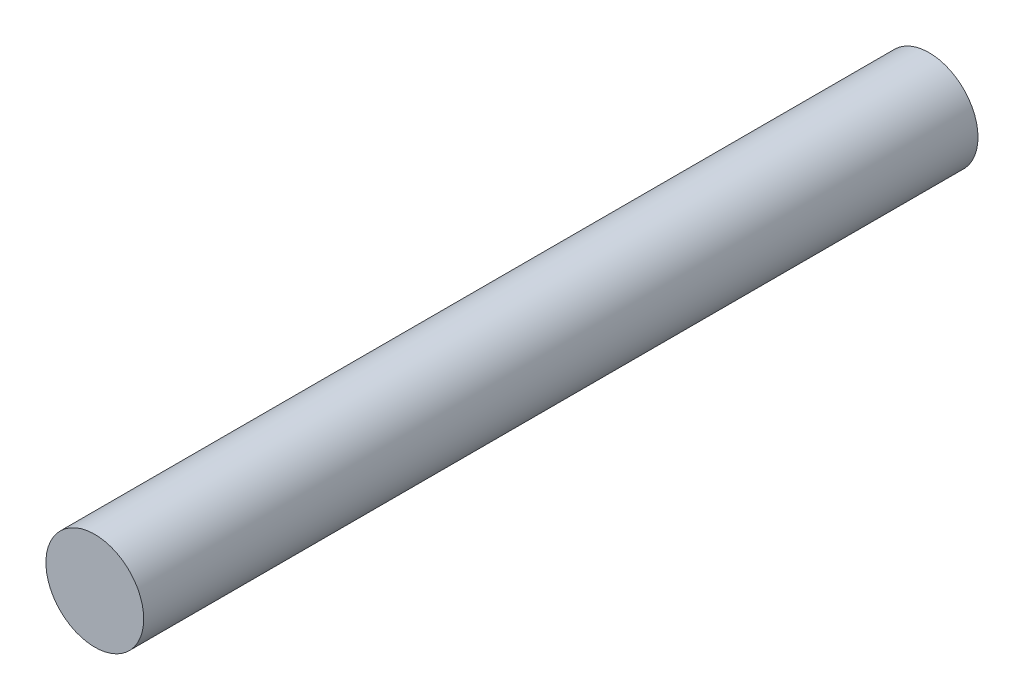
from build123d import *

# Parameters (mm, degrees)
SKETCH1_R           = 2.38125
BOSS_EXTRUDE1_DEPTH = 40.64


with BuildPart() as part:
    # Sketch1 → Boss-Extrude1 (new body)
    with BuildSketch(Plane.XY):
        Circle(SKETCH1_R)
    extrude(amount=BOSS_EXTRUDE1_DEPTH)


solid = part.part
